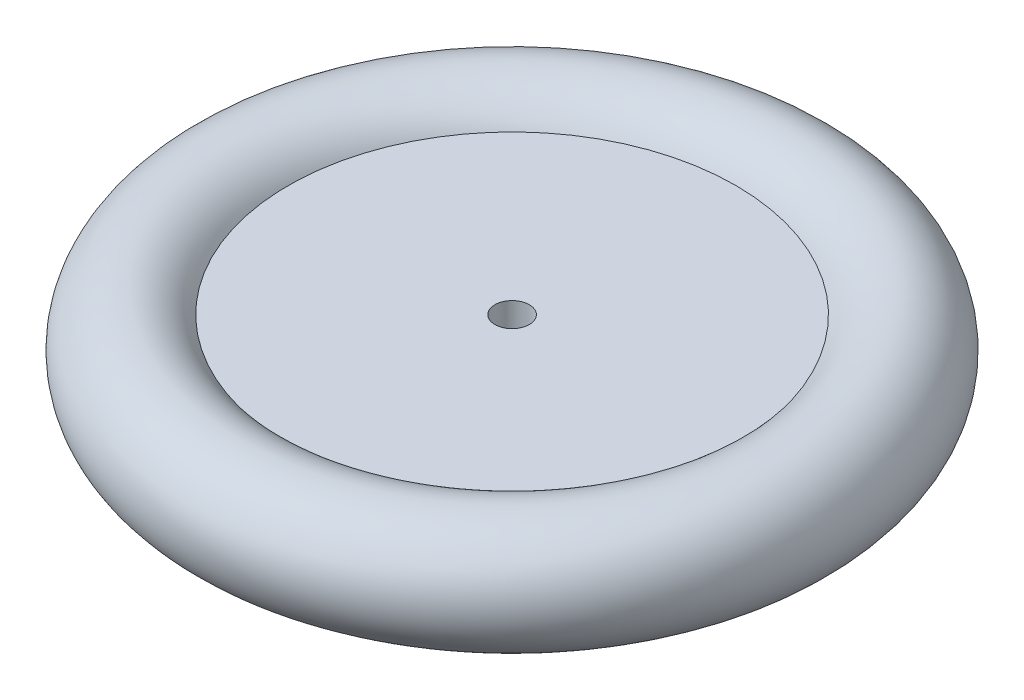
from build123d import *


with BuildPart() as part:
    # 草图1 → 旋转1 (revolve)
    with BuildSketch(Plane.XY):
        with BuildLine():
            Line((1.5, -3), (20, -3))
            ThreePointArc((20, -3), (28.711118693, 0.746759891), (19.5, 3))
            Line((19.5, 3), (1.5, 3))
            Line((1.5, 3), (1.5, -3))
        make_face()
    revolve(axis=Axis((0, 0, 0), (0, 1, 0)))


solid = part.part
